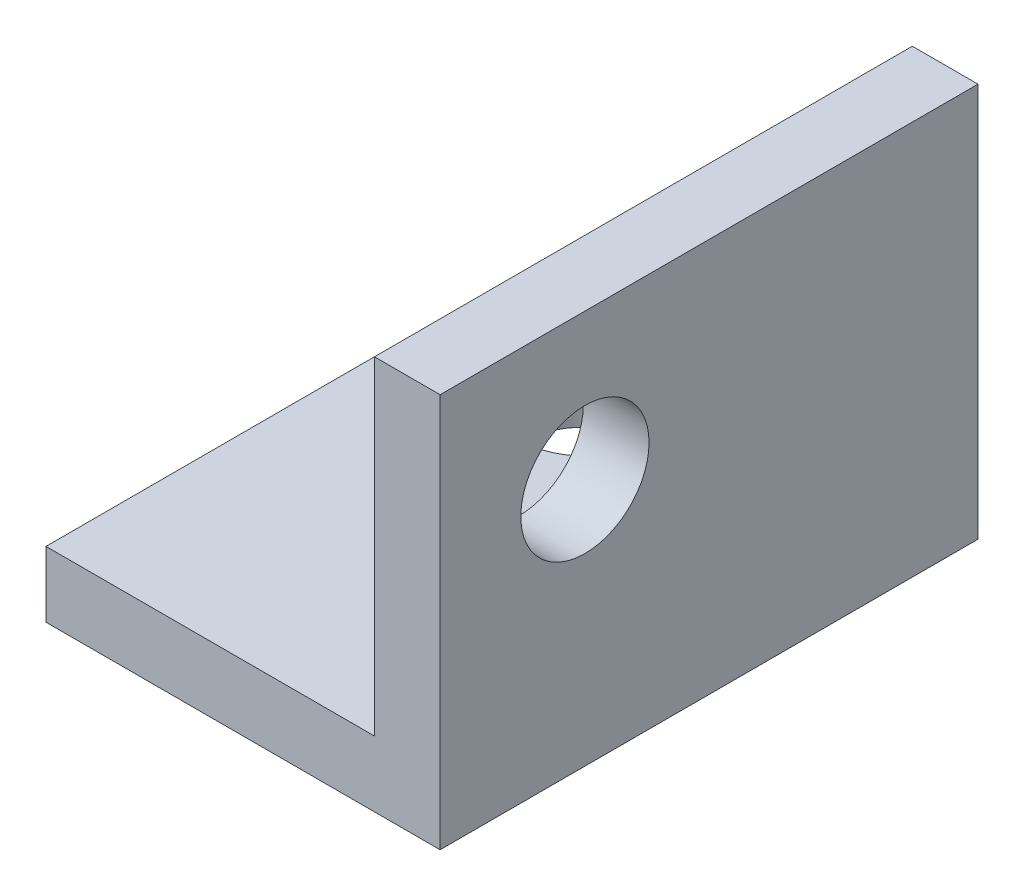
from build123d import *

# Parameters (mm, degrees)
BOSS_EXTRUDE1_DEPTH = 6.5
SKETCH4_R           = 1.55
CUT_EXTRUDE1_DEPTH  = 10
SKETCH5_R           = 1.55
CUT_EXTRUDE2_DEPTH  = 10


with BuildPart() as part:
    # Sketch3 → Boss-Extrude1 (new body, symmetric)
    with BuildSketch(Plane.XY):
        Polygon((3.175, -3.175), (-4.7625, -3.175), (-4.7625, -4.7625), (4.7625, -4.7625), (4.7625, 4.7625), (3.175, 4.7625), align=None)
    extrude(amount=BOSS_EXTRUDE1_DEPTH, both=True)

    # Sketch4 → Cut-Extrude1 (cut)
    with BuildSketch(Plane(origin=(4.7625, 0, 0), x_dir=(0, 0, -1), z_dir=(1, 0, 0))):
        with Locations((-3, 1.2375)):
            Circle(SKETCH4_R)
    extrude(amount=-CUT_EXTRUDE1_DEPTH, mode=Mode.SUBTRACT)

    # Sketch5 → Cut-Extrude2 (cut)
    with BuildSketch(Plane.XZ.offset(4.7625)):
        with Locations((-1.2375, -3)):
            Circle(SKETCH5_R)
    extrude(amount=-CUT_EXTRUDE2_DEPTH, mode=Mode.SUBTRACT)


solid = part.part
